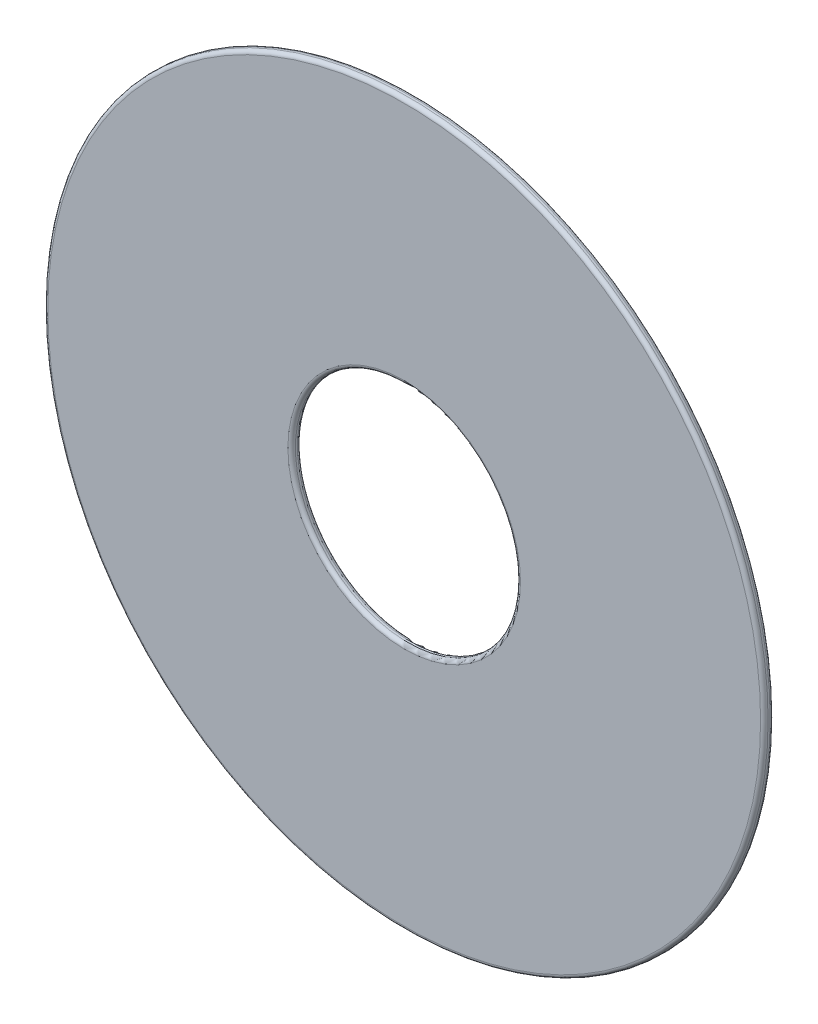
from build123d import *

# Parameters (mm, degrees)
SKETCH1_R           = 24
SKETCH1_R_2         = 7.5
BOSS_EXTRUDE1_DEPTH = 0.64
FILLET1_R           = 0.25


with BuildPart() as part:
    # Sketch1 → Boss-Extrude1 (new body)
    with BuildSketch(Plane.XY):
        Circle(SKETCH1_R)
        Circle(SKETCH1_R_2, mode=Mode.SUBTRACT)
    extrude(amount=BOSS_EXTRUDE1_DEPTH)

    # Fillet1
    fillet1_edges = [part.edges().sort_by_distance(p)[0] for p in [
        (-24, 0, 0),
        (-24, 0, 0.64),
        (-7.5, 0, 0),
        (-7.5, 0, 0.64),
    ]]
    fillet(fillet1_edges, radius=FILLET1_R)


solid = part.part
